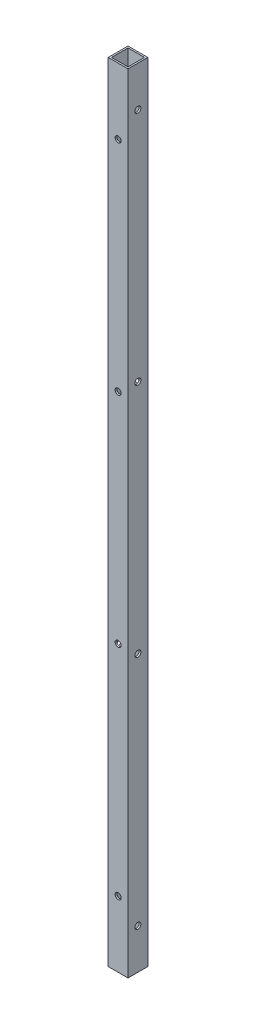
from build123d import *

# Parameters (mm, degrees)
SKETCH1_W             = 19.05
SKETCH1_H             = 19.05
SKETCH1_W_2           = 15.875
SKETCH1_H_2           = 15.875
TUBE_DEPTH            = 758.9266
SKETCH2_R             = 2.8956
SIDE_WALL_HOLES_DEPTH = 20.05
LPATTERN1_COUNT       = 4
LPATTERN1_PITCH       = 210.574466667
SKETCH3_R             = 2.8956
REARWALLHOLES_DEPTH   = 20.05
LPATTERN2_COUNT       = 4
LPATTERN2_PITCH       = 227.084466667


with BuildPart() as part:
    # Sketch1 → Tube (new body)
    with BuildSketch(Plane(origin=(0, 0, 0), x_dir=(1, 0, 0), z_dir=(0, 1, 0))):
        Rectangle(SKETCH1_W, SKETCH1_H)
        Rectangle(SKETCH1_W_2, SKETCH1_H_2, mode=Mode.SUBTRACT)
    extrude(amount=TUBE_DEPTH)

    # Sketch2 → Side Wall Holes (cut, through all)
    with BuildSketch(Plane.XY.offset(9.525)):
        with Locations((0, 695.325)):
            Circle(SKETCH2_R)
    side_wall_holes = extrude(amount=-SIDE_WALL_HOLES_DEPTH, mode=Mode.SUBTRACT)

    # LPattern1: Side Wall Holes ×4
    with Locations(*[(0, -i * LPATTERN1_PITCH, 0) for i in range(1, LPATTERN1_COUNT)]):
        add(side_wall_holes, mode=Mode.SUBTRACT)

    # Sketch3 → RearWallHoles (cut, through all)
    with BuildSketch(Plane.ZY.offset(9.525)):
        with Locations((0, 720.09)):
            Circle(SKETCH3_R)
    rearwallholes = extrude(amount=-REARWALLHOLES_DEPTH, mode=Mode.SUBTRACT)

    # LPattern2: RearWallHoles ×4
    with Locations(*[(0, -i * LPATTERN2_PITCH, 0) for i in range(1, LPATTERN2_COUNT)]):
        add(rearwallholes, mode=Mode.SUBTRACT)


solid = part.part
